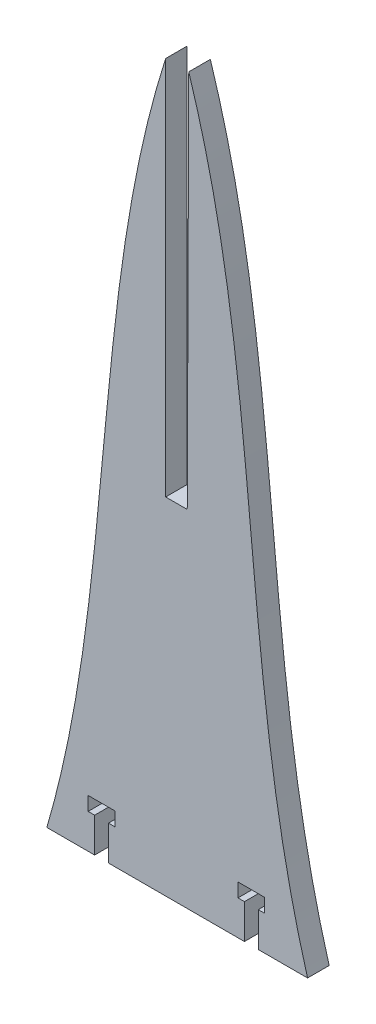
from build123d import *

# Parameters (mm, degrees)
BOSS_EXTRUDE1_DEPTH = 6.35


with BuildPart() as part:
    # Sketch1 → Boss-Extrude1 (new body)
    with BuildSketch(Plane.XY):
        with BuildLine():
            Line((-41.275, 0), (-27.223297828, 0))
            Line((-27.223297828, 0), (-27.223297828, 10.16))
            Line((-27.223297828, 10.16), (-29.128297828, 10.16))
            Line((-29.128297828, 10.16), (-29.128297828, 14.224))
            Line((-29.128297828, 14.224), (-21.254297828, 14.224))
            Line((-21.254297828, 14.224), (-21.254297828, 10.16))
            Line((-21.254297828, 10.16), (-23.159297828, 10.16))
            Line((-23.159297828, 10.16), (-23.159297828, 0))
            Line((-23.159297828, 0), (16.809297828, 0))
            Line((16.809297828, 0), (16.809297828, 10.16))
            Line((16.809297828, 10.16), (14.904297828, 10.16))
            Line((14.904297828, 10.16), (14.904297828, 14.224))
            Line((14.904297828, 14.224), (22.778297828, 14.224))
            Line((22.778297828, 14.224), (22.778297828, 10.16))
            Line((22.778297828, 10.16), (20.873297828, 10.16))
            Line((20.873297828, 10.16), (20.873297828, 0))
            Line((20.873297828, 0), (35.369845619, 0))
            add(Edge.make_bspline(
                [(0.444845619, 213.232011469), (22.600754388, 143.751265393), (14.929286493, 69.840750236), (35.369845619, 0)],
                knots=[0, 0, 0, 0, 1, 1, 1, 1], degree=3))
            Line((0.444845619, 213.232011469), (0, 101.6))
            Line((0, 101.6), (-6.35, 101.6))
            Line((-6.35, 101.6), (-6.35, 213.232011469))
            add(Edge.make_bspline(
                [(-6.35, 213.232011469), (-28.505908769, 143.751265393), (-20.834440874, 69.840750236), (-41.275, 0)],
                knots=[0, 0, 0, 0, 1, 1, 1, 1], degree=3))
        make_face()
    extrude(amount=BOSS_EXTRUDE1_DEPTH)


solid = part.part
